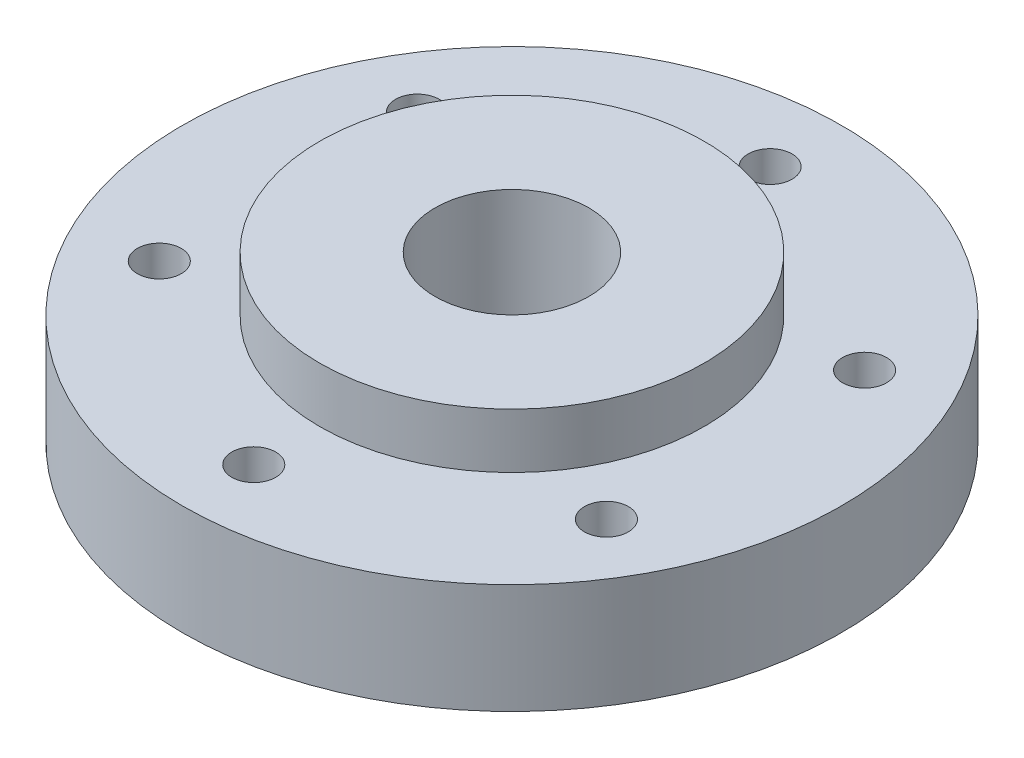
from build123d import *

# Parameters (mm, degrees)
SKETCH1_R           = 30
BOSS_EXTRUDE1_DEPTH = 15
SKETCH3_R           = 16.25
CUT_EXTRUDE1_DEPTH  = 5
SKETCH4_R           = 7
CUT_EXTRUDE2_DEPTH  = 11
SKETCH5_R           = 30
SKETCH5_R_2         = 17.5
CUT_EXTRUDE3_DEPTH  = 5
SKETCH6_R           = 2
CUT_EXTRUDE4_DEPTH  = 11


with BuildPart() as part:
    # Sketch1 → Boss-Extrude1 (new body)
    with BuildSketch(Plane(origin=(0, 0, 0), x_dir=(1, 0, 0), z_dir=(0, 1, 0))):
        Circle(SKETCH1_R)
    extrude(amount=BOSS_EXTRUDE1_DEPTH)

    # Sketch3 → Cut-Extrude1 (cut)
    with BuildSketch(Plane.XZ):
        Circle(SKETCH3_R)
    extrude(amount=-CUT_EXTRUDE1_DEPTH, mode=Mode.SUBTRACT)

    # Sketch4 → Cut-Extrude2 (cut, through all)
    with BuildSketch(Plane.XZ.offset(-5)):
        Circle(SKETCH4_R)
    extrude(amount=-CUT_EXTRUDE2_DEPTH, mode=Mode.SUBTRACT)

    # Sketch5 → Cut-Extrude3 (cut)
    with BuildSketch(Plane(origin=(0, 15, 0), x_dir=(1, 0, 0), z_dir=(0, 1, 0))):
        Circle(SKETCH5_R)
        Circle(SKETCH5_R_2, mode=Mode.SUBTRACT)
    extrude(amount=-CUT_EXTRUDE3_DEPTH, mode=Mode.SUBTRACT)

    # Sketch6 → Cut-Extrude4 (cut, through all)
    with BuildSketch(Plane(origin=(0, 10, 0), x_dir=(1, 0, 0), z_dir=(0, 1, 0))):
        with Locations((0, 23.5)):
            Circle(SKETCH6_R)
        with Locations((20.351596989, 11.75)):
            Circle(SKETCH6_R)
        with Locations((20.351596989, -11.75)):
            Circle(SKETCH6_R)
        with Locations((0, -23.5)):
            Circle(SKETCH6_R)
        with Locations((-20.351596989, -11.75)):
            Circle(SKETCH6_R)
        with Locations((-20.351596989, 11.75)):
            Circle(SKETCH6_R)
    extrude(amount=-CUT_EXTRUDE4_DEPTH, mode=Mode.SUBTRACT)


solid = part.part
